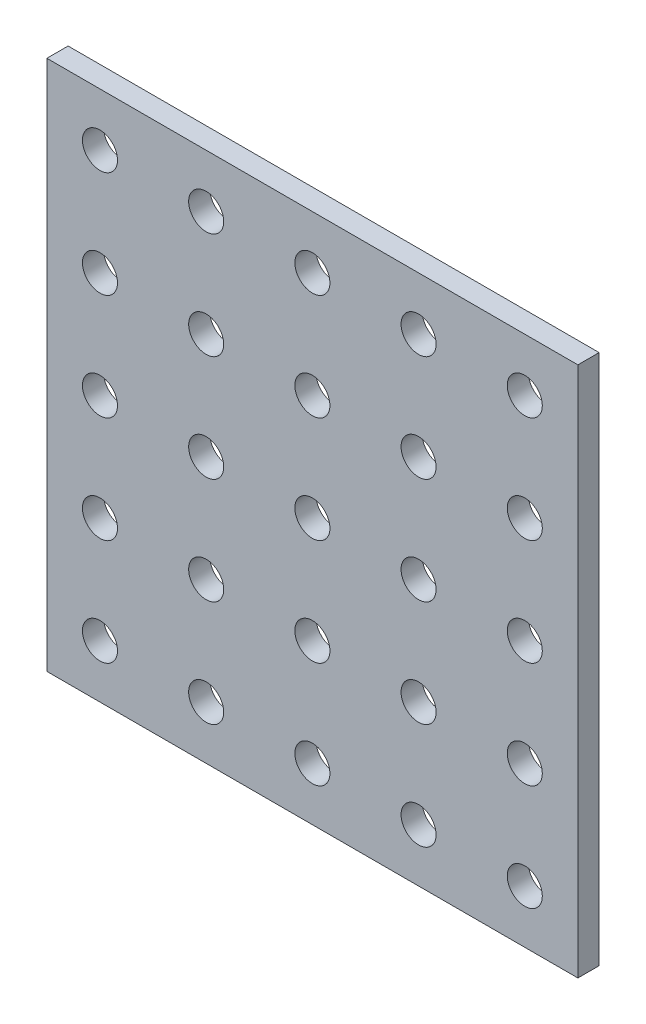
from build123d import *

# Parameters (mm, degrees)
SKETCH1_W            = 50
SKETCH1_H            = 50
BOSS_EXTRUDE1_DEPTH  = 2
SKETCH2_R            = 1.65
CUT_EXTRUDE1_DEPTH   = 3
LPATTERN1_COUNT      = 5
LPATTERN1_PITCH      = 10
LPATTERN1_COUNT_DIR2 = 5
LPATTERN1_PITCH_DIR2 = 10


with BuildPart() as part:
    # Sketch1 → Boss-Extrude1 (new body)
    with BuildSketch(Plane.XY):
        Rectangle(SKETCH1_W, SKETCH1_H)
    extrude(amount=BOSS_EXTRUDE1_DEPTH)

    # Sketch2 → Cut-Extrude1 (cut, through all)
    with BuildSketch(Plane.XY.offset(2)):
        with Locations((-20, 20)):
            Circle(SKETCH2_R)
    cut_extrude1 = extrude(amount=-CUT_EXTRUDE1_DEPTH, mode=Mode.SUBTRACT)

    # LPattern1: Cut-Extrude1 5 × 5
    with Locations(*[(j * LPATTERN1_PITCH_DIR2, -i * LPATTERN1_PITCH, 0) for i in range(LPATTERN1_COUNT) for j in range(LPATTERN1_COUNT_DIR2) if (i, j) != (0, 0)]):
        add(cut_extrude1, mode=Mode.SUBTRACT)


solid = part.part
